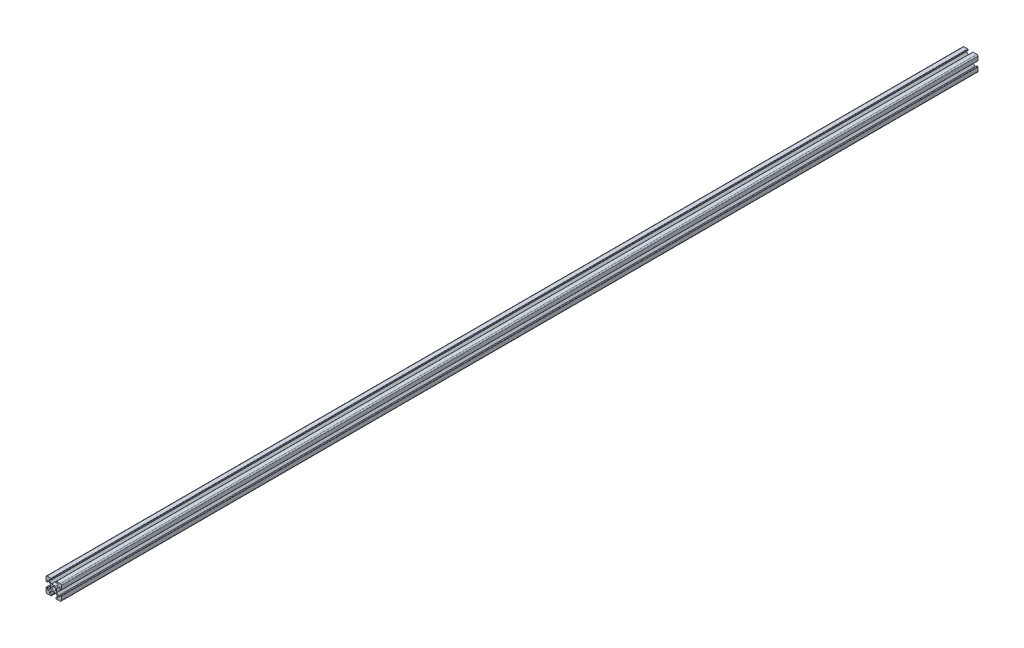
from build123d import *

# Parameters (mm, degrees)
SKETCH_1_R      = 2.5
EXTRUDE_1_DEPTH = 1200
FILLET_1_R      = 1.5
FILLET_2_R      = 1.5
FILLET_3_R      = 1.5
FILLET_4_R      = 1.5
FILLET_5_R      = 0.5
FILLET_6_R      = 0.5
FILLET_7_R      = 0.5
FILLET_8_R      = 0.5
FILLET_9_R      = 0.5
FILLET_10_R     = 0.5
FILLET_11_R     = 0.5
FILLET_12_R     = 0.5


with BuildPart() as part:
    # 草图1 → 凸台-拉伸1 (new body)
    with BuildSketch(Plane.XY):
        Polygon((0, 6.9), (0, 0), (6.9, 0), (6.9, 1.8), (4.5, 1.8), (4.5, 3.227207794), (7.372792206, 6.1), (12.627207794, 6.1), (15.5, 3.227207794), (15.5, 1.8), (13.1, 1.8), (13.1, 0), (20, 0), (20, 6.9), (18.2, 6.9), (18.2, 4.5), (16.772792206, 4.5), (13.9, 7.372792206), (13.9, 12.627207794), (16.772792206, 15.5), (18.2, 15.5), (18.2, 13.1), (20, 13.1), (20, 20), (13.1, 20), (13.1, 18.2), (15.5, 18.2), (15.5, 16.772792206), (12.627207794, 13.9), (7.372792206, 13.9), (4.5, 16.772792206), (4.5, 18.2), (6.9, 18.2), (6.9, 20), (0, 20), (0, 13.1), (1.8, 13.1), (1.8, 15.5), (3.227207794, 15.5), (6.1, 12.627207794), (6.1, 7.372792206), (3.227207794, 4.5), (1.8, 4.5), (1.8, 6.9), align=None)
        with Locations((10, 10)):
            Circle(SKETCH_1_R, mode=Mode.SUBTRACT)
    extrude(amount=EXTRUDE_1_DEPTH)

    # 圆角1
    fillet_1_edges = [part.edges().sort_by_distance(p)[0] for p in [
        (20, 20, 600),
    ]]
    fillet(fillet_1_edges, radius=FILLET_1_R)

    # 圆角2
    fillet_2_edges = [part.edges().sort_by_distance(p)[0] for p in [
        (0, 20, 600),
    ]]
    fillet(fillet_2_edges, radius=FILLET_2_R)

    # 圆角3
    fillet_3_edges = [part.edges().sort_by_distance(p)[0] for p in [
        (0, 0, 600),
    ]]
    fillet(fillet_3_edges, radius=FILLET_3_R)

    # 圆角4
    fillet_4_edges = [part.edges().sort_by_distance(p)[0] for p in [
        (20, 0, 600),
    ]]
    fillet(fillet_4_edges, radius=FILLET_4_R)

    # 圆角5
    fillet_5_edges = [part.edges().sort_by_distance(p)[0] for p in [
        (13.1, 20, 600),
    ]]
    fillet(fillet_5_edges, radius=FILLET_5_R)

    # 圆角6
    fillet_6_edges = [part.edges().sort_by_distance(p)[0] for p in [
        (6.9, 20, 600),
    ]]
    fillet(fillet_6_edges, radius=FILLET_6_R)

    # 圆角7
    fillet_7_edges = [part.edges().sort_by_distance(p)[0] for p in [
        (0, 13.1, 600),
    ]]
    fillet(fillet_7_edges, radius=FILLET_7_R)

    # 圆角8
    fillet_8_edges = [part.edges().sort_by_distance(p)[0] for p in [
        (0, 6.9, 600),
    ]]
    fillet(fillet_8_edges, radius=FILLET_8_R)

    # 圆角9
    fillet_9_edges = [part.edges().sort_by_distance(p)[0] for p in [
        (6.9, 0, 600),
    ]]
    fillet(fillet_9_edges, radius=FILLET_9_R)

    # 圆角10
    fillet_10_edges = [part.edges().sort_by_distance(p)[0] for p in [
        (13.1, 0, 600),
    ]]
    fillet(fillet_10_edges, radius=FILLET_10_R)

    # 圆角11
    fillet_11_edges = [part.edges().sort_by_distance(p)[0] for p in [
        (20, 13.1, 600),
    ]]
    fillet(fillet_11_edges, radius=FILLET_11_R)

    # 圆角12
    fillet_12_edges = [part.edges().sort_by_distance(p)[0] for p in [
        (20, 6.9, 600),
    ]]
    fillet(fillet_12_edges, radius=FILLET_12_R)


solid = part.part
